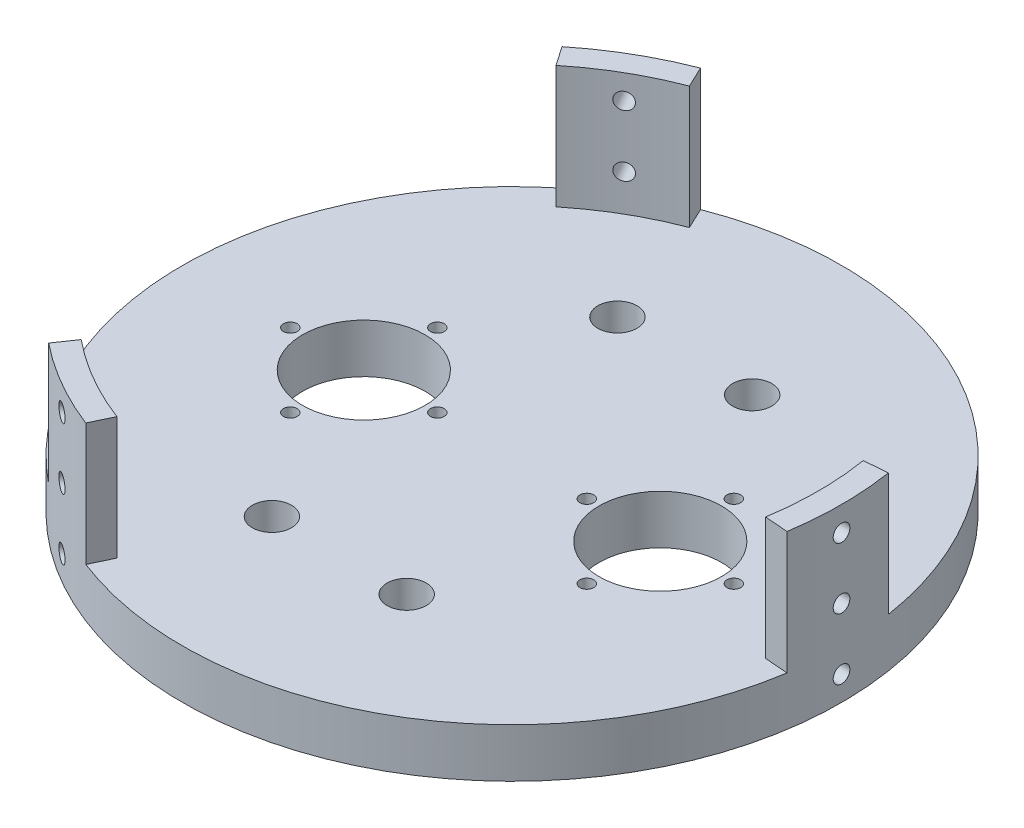
from build123d import *

# Parameters (mm, degrees)
SKETCH1_W           = 127.635
SKETCH1_H           = 127.635
MAIN_PLATE_DEPTH    = 12.7
SKETCH9_R           = 85.725
BOSS_EXTRUDE1_DEPTH = 12.7
SKETCH10_R          = 95.25
SKETCH10_R_2        = 85.4075
CUT_EXTRUDE1_DEPTH  = 167.64
SKETCH18_R          = 85.4075
SKETCH18_R_2        = 79.375
BOSS_EXTRUDE2_DEPTH = 38.1
SKETCH15_R          = 2.159
CUT_EXTRUDE3_DEPTH  = 88.9
CIRPATTERN1_COUNT   = 3
SKETCH21_R          = 15.875
SKETCH21_R_2        = 1.778
CO2_MOUNTS_DEPTH    = 13.7000001
SKETCH22_R          = 5.08
CUT_EXTRUDE5_DEPTH  = 13.7000001
SKETCH23_R          = 79.375
CUT_EXTRUDE6_DEPTH  = 111.600000066


with BuildPart() as part:
    # Sketch1 → Main Plate (new body)
    with BuildSketch(Plane(origin=(0, 0, 0), x_dir=(1, 0, 0), z_dir=(0, 1, 0))):
        with Locations((63.8175, 63.8175)):
            Rectangle(SKETCH1_W, SKETCH1_H)
    extrude(amount=MAIN_PLATE_DEPTH)

    # Sketch9 → Boss-Extrude1 (add)
    with BuildSketch(Plane(origin=(0, 12.7, 0), x_dir=(1, 0, 0), z_dir=(0, 1, 0))):
        with Locations((63.8175, 63.8175)):
            Circle(SKETCH9_R)
    extrude(amount=-BOSS_EXTRUDE1_DEPTH)

    # Sketch10 → Cut-Extrude1 (cut)
    with BuildSketch(Plane(origin=(0, 12.7, 0), x_dir=(1, 0, 0), z_dir=(0, 1, 0))):
        with Locations((63.8175, 63.8175)):
            Circle(SKETCH10_R)
        with Locations((63.8175, 63.8175)):
            Circle(SKETCH10_R_2, mode=Mode.SUBTRACT)
    extrude(amount=-CUT_EXTRUDE1_DEPTH, mode=Mode.SUBTRACT)

    # Sketch18 → Boss-Extrude2 (add)
    with BuildSketch(Plane(origin=(0, 6.35, 0), x_dir=(1, 0, 0), z_dir=(0, 1, 0))):
        with Locations((63.8175, 63.8175)):
            Circle(SKETCH18_R)
        with Locations((63.8175, 63.8175)):
            Circle(SKETCH18_R_2, mode=Mode.SUBTRACT)
    extrude(amount=BOSS_EXTRUDE2_DEPTH)

    # Sketch15 → Cut-Extrude3 (cut)
    with BuildSketch(Plane(origin=(166.221610148, 0, 178.614251028), x_dir=(-0.866025404, 0, -0.5), z_dir=(0.5, 0, -0.866025404))):
        with Locations((209.900436354, 22.225)):
            Circle(SKETCH15_R)
        with Locations((209.900436354, 38.1)):
            Circle(SKETCH15_R)
        with Locations((209.900436354, 6.35)):
            Circle(SKETCH15_R)
    cut_extrude3 = extrude(amount=CUT_EXTRUDE3_DEPTH, mode=Mode.SUBTRACT)

    # CirPattern1: Cut-Extrude3 ×3 about axis
    cirpattern1_axis = Axis((63.8175, 0, -63.8175), (0, 1, 0))
    for i in range(1, CIRPATTERN1_COUNT):
        add(cut_extrude3.rotate(cirpattern1_axis, i * 360 / CIRPATTERN1_COUNT), mode=Mode.SUBTRACT)

    # Sketch21 → CO2 Mounts (cut, through all)
    with BuildSketch(Plane(origin=(0, 12.7, 0), x_dir=(1, 0, 0), z_dir=(0, 1, 0))):
        with Locations((102.235, 63.8175)):
            Circle(SKETCH21_R)
        with Locations((102.235, 82.8675)):
            Circle(SKETCH21_R_2)
        with Locations((25.4, 63.8175)):
            Circle(SKETCH21_R)
        with Locations((121.285, 63.8175)):
            Circle(SKETCH21_R_2)
        with Locations((102.235, 44.7675)):
            Circle(SKETCH21_R_2)
        with Locations((83.185, 63.8175)):
            Circle(SKETCH21_R_2)
        with Locations((25.4, 82.8675)):
            Circle(SKETCH21_R_2)
        with Locations((6.35, 63.8175)):
            Circle(SKETCH21_R_2)
        with Locations((25.4, 44.7675)):
            Circle(SKETCH21_R_2)
        with Locations((44.45, 63.8175)):
            Circle(SKETCH21_R_2)
    extrude(amount=-CO2_MOUNTS_DEPTH, mode=Mode.SUBTRACT)

    # Sketch22 → Cut-Extrude5 (cut, through all)
    with BuildSketch(Plane(origin=(0, 12.7, 0), x_dir=(1, 0, 0), z_dir=(0, 1, 0))):
        with Locations((46.355, 108.585)):
            Circle(SKETCH22_R)
        with Locations((81.28, 108.585)):
            Circle(SKETCH22_R)
        with Locations((81.28, 19.05)):
            Circle(SKETCH22_R)
        with Locations((46.355, 19.05)):
            Circle(SKETCH22_R)
    extrude(amount=-CUT_EXTRUDE5_DEPTH, mode=Mode.SUBTRACT)

    # Sketch23 → Cut-Extrude6 (cut)
    with BuildSketch(Plane(origin=(0, 12.7, 0), x_dir=(1, 0, 0), z_dir=(0, 1, 0))):
        with Locations((63.8175, 63.8175)):
            Circle(SKETCH23_R)
        with BuildLine():
            Line((13.678739997, 125.352005526), (7.552270878, 134.237860218))
            Line((7.552270878, 134.237860218), (-19.267108419, 125.320629884))
            Line((-19.267108419, 125.320629884), (-48.79695837, 60.397770071))
            Line((-48.79695837, 60.397770071), (-9.884344094, 7.052469015))
            Line((-9.884344094, 7.052469015), (6.959175986, -7.46308736))
            Line((6.959175986, -7.46308736), (13.678739997, 2.282994474))
            ThreePointArc((13.678739997, 2.282994474), (-15.5575, 63.8175), (13.678739997, 125.352005526))
        make_face()
        with BuildLine():
            Line((142.177324996, 76.471687114), (152.935935453, 77.334437661))
            Line((152.935935453, 77.334437661), (158.623077101, 105.019316613))
            Line((158.623077101, 105.019316613), (117.163156193, 163.054346747))
            Line((117.163156193, 163.054346747), (51.508463168, 156.027684783))
            Line((51.508463168, 156.027684783), (30.515862556, 148.698546693))
            Line((30.515862556, 148.698546693), (35.596435007, 138.00619264))
            ThreePointArc((35.596435007, 138.00619264), (103.505, 132.558266425), (142.177324996, 76.471687114))
        make_face()
        with BuildLine():
            Line((35.596435007, -10.37119264), (30.964293669, -20.119797879))
            Line((30.964293669, -20.119797879), (52.096531318, -38.887446496))
            Line((52.096531318, -38.887446496), (123.086302178, -31.999616818))
            Line((123.086302178, -31.999616818), (149.828380926, 28.372346201))
            Line((149.828380926, 28.372346201), (153.977461458, 50.217040667))
            Line((153.977461458, 50.217040667), (142.177324996, 51.163312886))
            ThreePointArc((142.177324996, 51.163312886), (103.505, -4.923266425), (35.596435007, -10.37119264))
        make_face()
    extrude(amount=CUT_EXTRUDE6_DEPTH, mode=Mode.SUBTRACT)


solid = part.part
